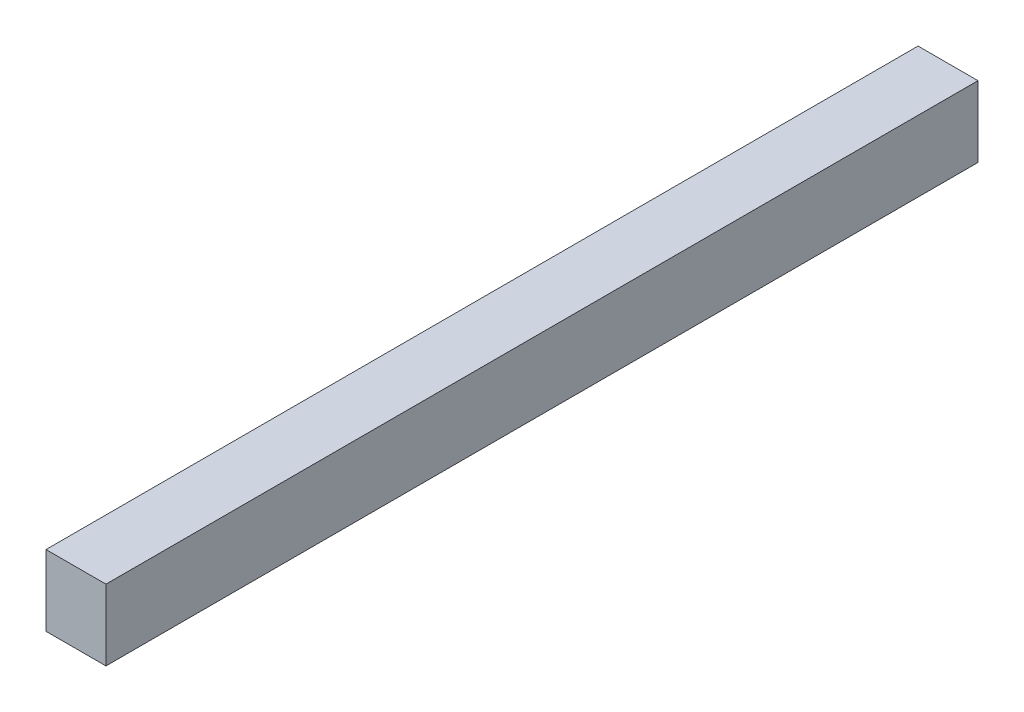
from build123d import *

# Parameters (mm, degrees)
SKETCH1_W           = 2.75
SKETCH1_H           = 3.25
BOSS_EXTRUDE1_DEPTH = 40


with BuildPart() as part:
    # Sketch1 → Boss-Extrude1 (new body)
    with BuildSketch(Plane.XY):
        Rectangle(SKETCH1_W, SKETCH1_H)
    extrude(amount=BOSS_EXTRUDE1_DEPTH)


solid = part.part
